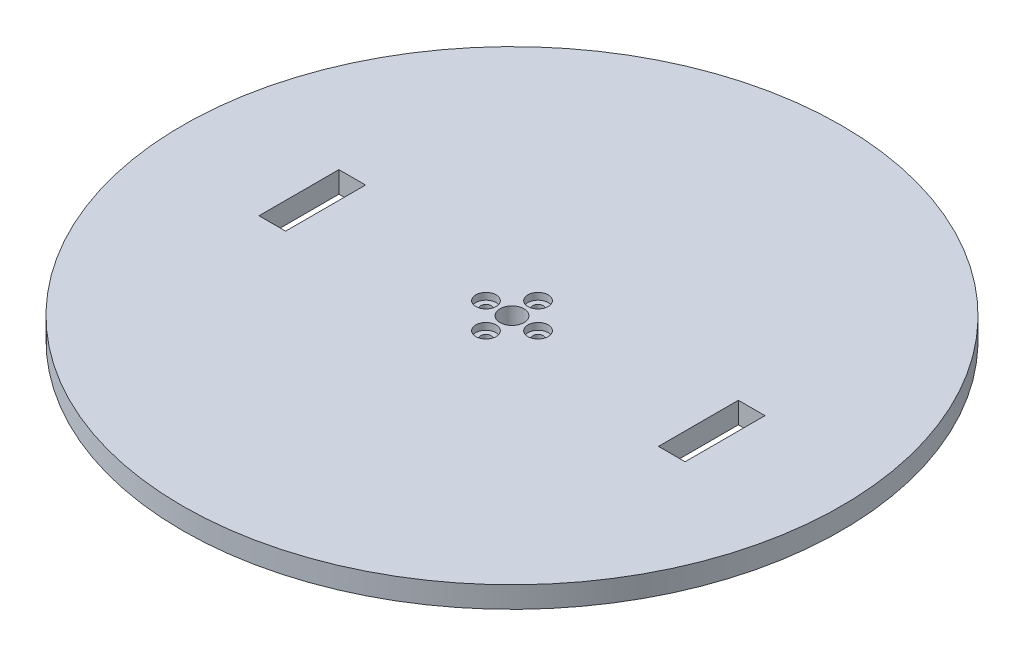
from build123d import *

# Parameters (mm, degrees)
SKETCH1_R           = 123.75
BOSS_EXTRUDE1_DEPTH = 8
SKETCH2_R           = 1.905
CUT_EXTRUDE2_DEPTH  = 9
CIRPATTERN1_COUNT   = 4
SKETCH3_R           = 4.5
CUT_EXTRUDE3_DEPTH  = 9
SKETCH4_R           = 3.81
CUT_EXTRUDE4_DEPTH  = 2.54
CIRPATTERN2_COUNT   = 4
SKETCH5_W           = 10
SKETCH5_H           = 30
CUT_EXTRUDE5_DEPTH  = 9


with BuildPart() as part:
    # Sketch1 → Boss-Extrude1 (new body)
    with BuildSketch(Plane(origin=(0, 0, 0), x_dir=(1, 0, 0), z_dir=(0, 1, 0))):
        Circle(SKETCH1_R)
    extrude(amount=BOSS_EXTRUDE1_DEPTH)

    # Sketch2 → Cut-Extrude2 (cut, through all)
    with BuildSketch(Plane(origin=(0, 8, 0), x_dir=(1, 0, 0), z_dir=(0, 1, 0))):
        with Locations((0, 9.779)):
            Circle(SKETCH2_R)
    cut_extrude2 = extrude(amount=-CUT_EXTRUDE2_DEPTH, mode=Mode.SUBTRACT)

    # CirPattern1: Cut-Extrude2 ×4 about axis
    cirpattern1_axis = Axis((0, 0, 0), (0, 1, 0))
    for i in range(1, CIRPATTERN1_COUNT):
        add(cut_extrude2.rotate(cirpattern1_axis, i * 360 / CIRPATTERN1_COUNT), mode=Mode.SUBTRACT)

    # Sketch3 → Cut-Extrude3 (cut, through all)
    with BuildSketch(Plane(origin=(0, 8, 0), x_dir=(1, 0, 0), z_dir=(0, 1, 0))):
        Circle(SKETCH3_R)
    extrude(amount=-CUT_EXTRUDE3_DEPTH, mode=Mode.SUBTRACT)

    # Sketch4 → Cut-Extrude4 (cut)
    with BuildSketch(Plane(origin=(0, 8, 0), x_dir=(1, 0, 0), z_dir=(0, 1, 0))):
        with Locations((0, 9.779)):
            Circle(SKETCH4_R)
    cut_extrude4 = extrude(amount=-CUT_EXTRUDE4_DEPTH, mode=Mode.SUBTRACT)

    # CirPattern2: Cut-Extrude4 ×4 about axis
    cirpattern2_axis = Axis((0, 0, 0), (0, 1, 0))
    for i in range(1, CIRPATTERN2_COUNT):
        add(cut_extrude4.rotate(cirpattern2_axis, i * 360 / CIRPATTERN2_COUNT), mode=Mode.SUBTRACT)

    # Sketch5 → Cut-Extrude5 (cut, through all)
    with BuildSketch(Plane(origin=(0, 8, 0), x_dir=(1, 0, 0), z_dir=(0, 1, 0))):
        with Locations((75, 0)):
            Rectangle(SKETCH5_W, SKETCH5_H)
        with Locations((-75, 0)):
            Rectangle(SKETCH5_W, SKETCH5_H)
    extrude(amount=-CUT_EXTRUDE5_DEPTH, mode=Mode.SUBTRACT)


solid = part.part
